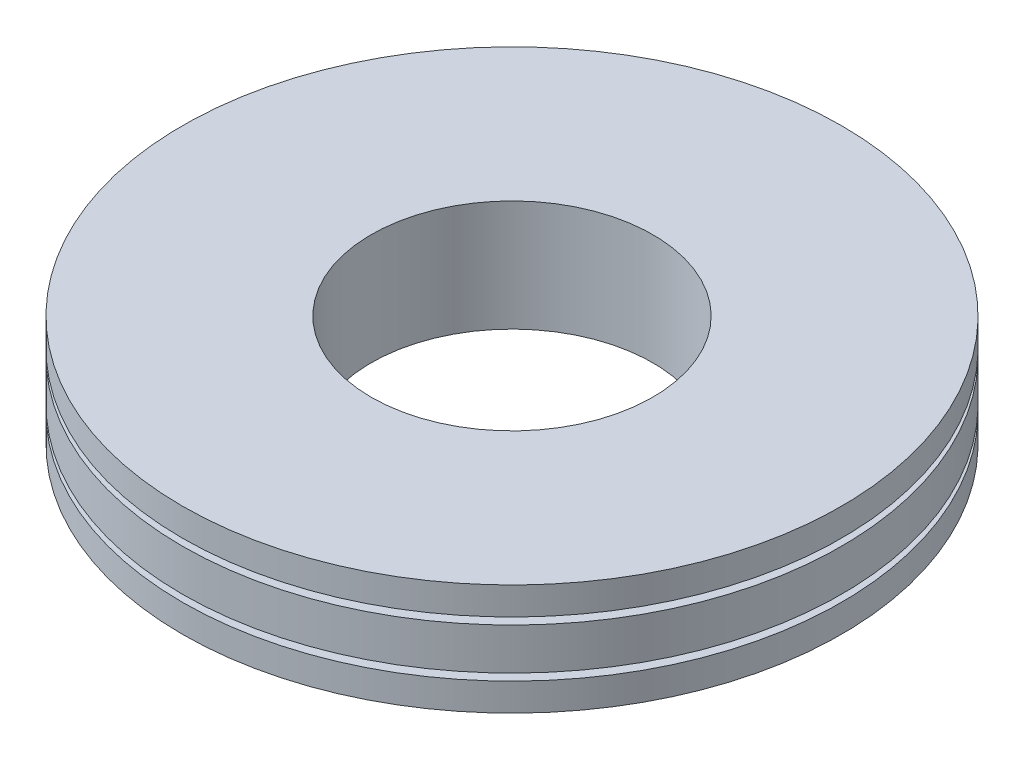
from build123d import *

# Parameters (mm, degrees)
SKETCH1_R           = 11.875
SKETCH1_R_2         = 5.075
BOSS_EXTRUDE1_DEPTH = 2
SKETCH2_R           = 11.875
SKETCH2_R_2         = 11.375
CUT_EXTRUDE1_DEPTH  = 0.25


with BuildPart() as part:
    # Sketch1 → Boss-Extrude1 (new body, symmetric)
    with BuildSketch(Plane(origin=(0, 0, 0), x_dir=(1, 0, 0), z_dir=(0, 1, 0))):
        Circle(SKETCH1_R)
        Circle(SKETCH1_R_2, mode=Mode.SUBTRACT)
    extrude(amount=BOSS_EXTRUDE1_DEPTH, both=True)

    # Sketch2 → Cut-Extrude1 (cut)
    with BuildSketch(Plane(origin=(0, 1, 0), x_dir=(1, 0, 0), z_dir=(0, 1, 0))):
        Circle(SKETCH2_R)
        Circle(SKETCH2_R_2, mode=Mode.SUBTRACT)
    cut_extrude1 = extrude(amount=-CUT_EXTRUDE1_DEPTH, mode=Mode.SUBTRACT)

    # Mirror1: Cut-Extrude1 across plane
    add(cut_extrude1.mirror(Plane.ZX), mode=Mode.SUBTRACT)


solid = part.part
